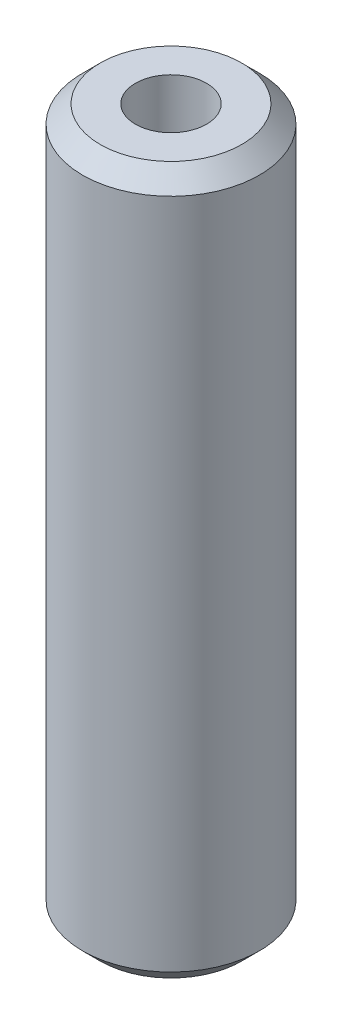
from build123d import *

# Parameters (mm, degrees)
SKETCH1_R                   = 6.35
BOSS_EXTRUDE1_DEPTH         = 50.8
CHAMFER1_SIZE               = 1.27
F_1_4_20_TAPPED_HOLE1_D     = 5.1054
F_1_4_20_TAPPED_HOLE1_DEPTH = 16.51
F_1_4_20_TAPPED_HOLE1_TIP   = 1.533816902
F_1_4_20_TAPPED_HOLE2_D     = 5.1054
F_1_4_20_TAPPED_HOLE2_DEPTH = 16.51
F_1_4_20_TAPPED_HOLE2_TIP   = 1.533816902


with BuildPart() as part:
    # Sketch1 → Boss-Extrude1 (new body)
    with BuildSketch(Plane(origin=(0, 0, 0), x_dir=(1, 0, 0), z_dir=(0, 1, 0))):
        Circle(SKETCH1_R)
    extrude(amount=BOSS_EXTRUDE1_DEPTH)

    # Chamfer1
    chamfer1_edges = [part.edges().sort_by_distance(p)[0] for p in [
        (-6.35, 0, 0),
        (-6.35, 50.8, 0),
    ]]
    chamfer(chamfer1_edges, length=CHAMFER1_SIZE)

    # 1/4-20 Tapped Hole1
    with Locations(Plane(origin=(0, 0, 0), x_dir=(-1, 0, 0), z_dir=(0, -1, 0))):
        with Locations((0, 0)):
            Hole(F_1_4_20_TAPPED_HOLE1_D / 2, depth=F_1_4_20_TAPPED_HOLE1_DEPTH)
            with Locations((0, 0, -(F_1_4_20_TAPPED_HOLE1_DEPTH + F_1_4_20_TAPPED_HOLE1_TIP / 2))):  # 118° drill point
                Cone(0, F_1_4_20_TAPPED_HOLE1_D / 2, F_1_4_20_TAPPED_HOLE1_TIP, mode=Mode.SUBTRACT)

    # 1/4-20 Tapped Hole2
    with Locations(Plane(origin=(0, 50.8, 0), x_dir=(1, 0, 0), z_dir=(0, 1, 0))):
        with Locations((0, 0)):
            Hole(F_1_4_20_TAPPED_HOLE2_D / 2, depth=F_1_4_20_TAPPED_HOLE2_DEPTH)
            with Locations((0, 0, -(F_1_4_20_TAPPED_HOLE2_DEPTH + F_1_4_20_TAPPED_HOLE2_TIP / 2))):  # 118° drill point
                Cone(0, F_1_4_20_TAPPED_HOLE2_D / 2, F_1_4_20_TAPPED_HOLE2_TIP, mode=Mode.SUBTRACT)


solid = part.part
